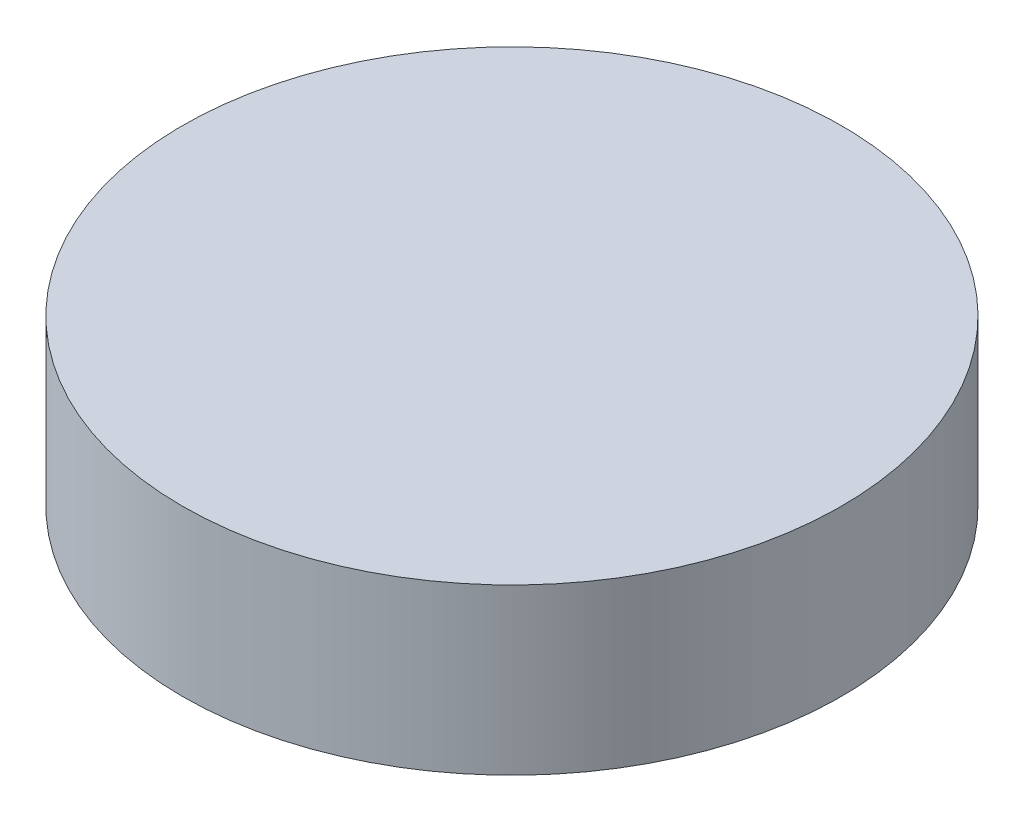
from build123d import *

# Parameters (mm, degrees)
SKETCH1_R           = 25.4
BOSS_EXTRUDE1_DEPTH = 6.35


with BuildPart() as part:
    # Sketch1 → Boss-Extrude1 (new body, symmetric)
    with BuildSketch(Plane(origin=(0, 0, 0), x_dir=(1, 0, 0), z_dir=(0, 1, 0))):
        Circle(SKETCH1_R)
    extrude(amount=BOSS_EXTRUDE1_DEPTH, both=True)


solid = part.part
